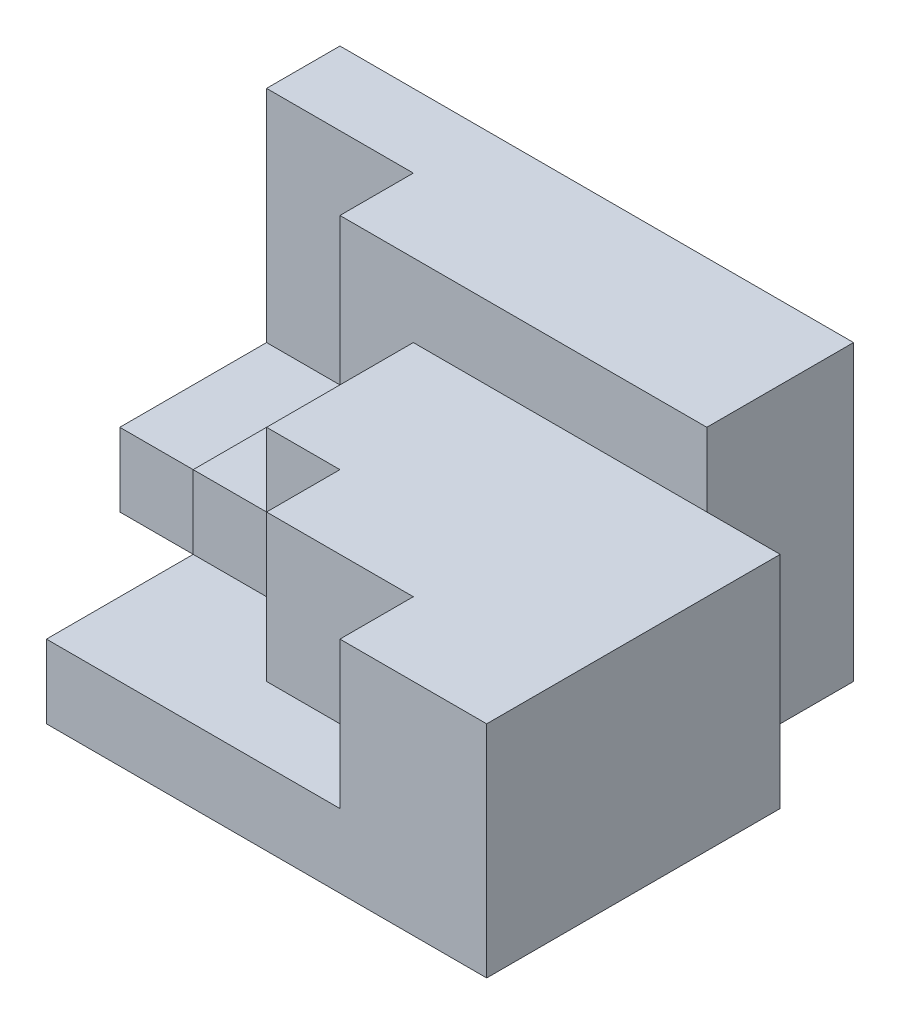
from build123d import *

# Parameters (mm, degrees)
BOSS_EXTRUDE1_DEPTH = 10
BOSS_EXTRUDE2_DEPTH = 20
BOSS_EXTRUDE3_DEPTH = 10
SKETCH4_W           = 10
SKETCH4_H           = 26.291217747
CUT_EXTRUDE1_DEPTH  = 10


with BuildPart() as part:
    # Sketch1 → Boss-Extrude1 (new body)
    with BuildSketch(Plane(origin=(0, 0, 0), x_dir=(1, 0, 0), z_dir=(0, 1, 0))):
        Polygon((0, 0), (-10, 0), (-10, 20), (-80, 20), (-80, -10), (-60, -10), (-60, -40), (0, -40), align=None)
    extrude(amount=BOSS_EXTRUDE1_DEPTH)

    # Sketch2 → Boss-Extrude2 (add)
    with BuildSketch(Plane(origin=(0, 10, 0), x_dir=(1, 0, 0), z_dir=(0, 1, 0))):
        Polygon((-10, 20), (-10, 0), (0, 0), (0, -40), (-20, -40), (-20, -30), (-40, -30), (-40, -20), (-60, -20), (-60, -10), (-60, 10), (-80, 10), (-80, 20), (-60, 20), align=None)
    extrude(amount=BOSS_EXTRUDE2_DEPTH)

    # Sketch3 → Boss-Extrude3 (add)
    with BuildSketch(Plane(origin=(0, 30, 0), x_dir=(1, 0, 0), z_dir=(0, 1, 0))):
        Polygon((-80, 20), (-10, 20), (-10, 0), (-60, 0), (-60, 10), (-80, 10), align=None)
    extrude(amount=BOSS_EXTRUDE3_DEPTH)

    # Sketch4 → Cut-Extrude1 (cut)
    with BuildSketch(Plane(origin=(0, 30, 0), x_dir=(1, 0, 0), z_dir=(0, 1, 0))):
        with Locations((-55, -13.145608874)):
            Rectangle(SKETCH4_W, SKETCH4_H)
    extrude(amount=-CUT_EXTRUDE1_DEPTH, mode=Mode.SUBTRACT)


solid = part.part
